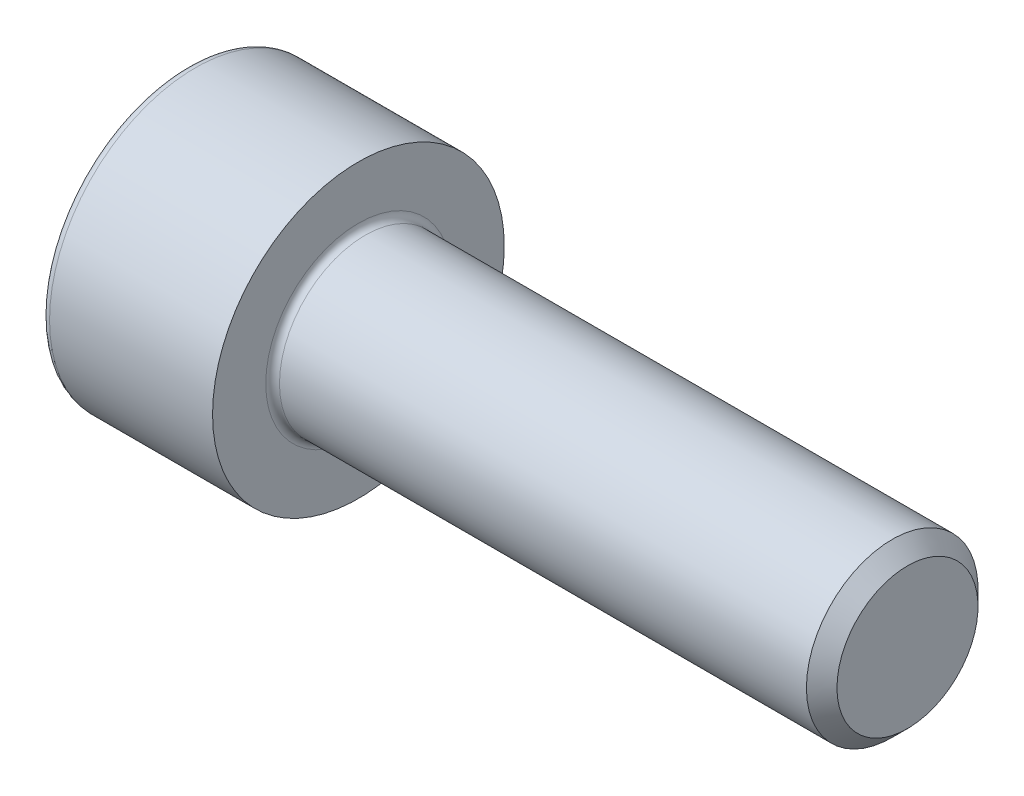
from build123d import *

# Parameters (mm, degrees)
FILLET1_R   = 0.2
FILLET2_R   = 0.25
HEX_2_DEPTH = 2.5


with BuildPart() as part:
    # BodySke → Base-Revolve (revolve)
    with BuildSketch(Plane.XY):
        Polygon((0, 0), (0, 4.25), (5, 4.25), (5, 2.5), (20.555, 2.5), (21, 2.055), (21, 0), align=None)
    revolve(axis=Axis((-31.75, 0, 0), (1, 0, 0)))

    # Fillet1
    fillet1_edges = [part.edges().sort_by_distance(p)[0] for p in [
        (5, -2.5, 0),
    ]]
    fillet(fillet1_edges, radius=FILLET1_R)

    # Fillet2
    fillet2_edges = [part.edges().sort_by_distance(p)[0] for p in [
        (0, -4.25, 0),
    ]]
    fillet(fillet2_edges, radius=FILLET2_R)

    # Sketch2 → Hex-PreBroach (revolve, cut)
    with BuildSketch(Plane.XY):
        Polygon((0, 2.042), (2.5, 2.042), (3.67894925, 0), (0, 0), align=None)
    revolve(axis=Axis((0, 0, 0), (1, 0, 0)), mode=Mode.SUBTRACT)

    # Sketch3 → Hex 2 (cut)
    with BuildSketch(Plane(origin=(0, 0, 0), x_dir=(0, 0.5, 0.866025404), z_dir=(-1, 0, 0))):
        Polygon((1.17894925, 2.042), (-1.17894925, 2.042), (-2.357898499, 0), (-1.17894925, -2.042), (1.17894925, -2.042), (2.357898499, 0), align=None)
    extrude(amount=-HEX_2_DEPTH, mode=Mode.SUBTRACT)


solid = part.part
